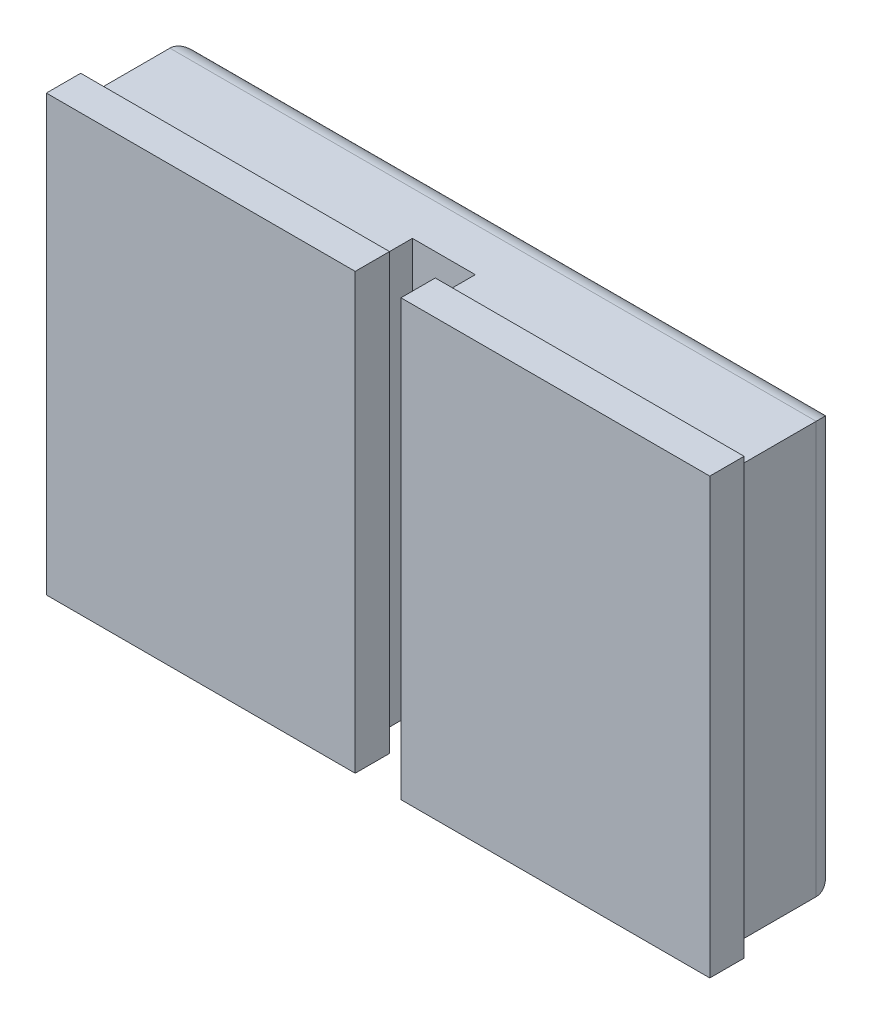
from build123d import *

# Parameters (mm, degrees)
SKETCH2_W             = 3.175
SKETCH2_H             = 4.572
BOSS_EXTRUDE1_DEPTH   = 0.762
SKETCH2_W_2           = 3.302
BOSS_EXTRUDE1_2_DEPTH = 0.762
BOSS_EXTRUDE2_DEPTH   = 0.7366
FILLET1_R             = 0.254
SKETCH4_W             = 3.429
SKETCH4_H             = 4.826
BOSS_EXTRUDE3_DEPTH   = 0.381


with BuildPart() as part:
    # Sketch2 → Boss-Extrude1 (new body)
    with BuildSketch(Plane.XY):
        Rectangle(SKETCH2_W, SKETCH2_H)
    extrude(amount=BOSS_EXTRUDE1_DEPTH)



with BuildPart() as body_2:
    # Sketch2 → Boss-Extrude1 2 (new body)
    with BuildSketch(Plane.XY):
        with Locations((3.937, 0)):
            Rectangle(SKETCH2_W_2, SKETCH2_H)
    extrude(amount=BOSS_EXTRUDE1_2_DEPTH)


with BuildPart() as part_1:
    add(part.part)

    add(body_2.part)  # Boss-Extrude2 merges body 2
    # Sketch3 → Boss-Extrude2 (add)
    with BuildSketch(Plane.XY):
        Polygon((-1.5875, -2.286), (1.5875, -2.286), (2.286, -2.286), (5.588, -2.286), (5.588, 2.286), (2.286, 2.286), (1.5875, 2.286), (-1.5875, 2.286), align=None)
    extrude(amount=-BOSS_EXTRUDE2_DEPTH)

    # Fillet1
    fillet1_edges = [part_1.edges().sort_by_distance(p)[0] for p in [
        (2.00025, 2.286, -0.7366),
        (5.588, 0, -0.7366),
        (2.00025, -2.286, -0.7366),
        (-1.5875, 0, -0.7366),
    ]]
    fillet(fillet1_edges, radius=FILLET1_R)

    # Sketch4 → Boss-Extrude3 (add)
    with BuildSketch(Plane.XY.offset(0.762)):
        Rectangle(SKETCH4_W, SKETCH4_H)
        with Locations((3.937, 0)):
            Rectangle(SKETCH4_W, SKETCH4_H)
    extrude(amount=-BOSS_EXTRUDE3_DEPTH)


solid = part_1.part
